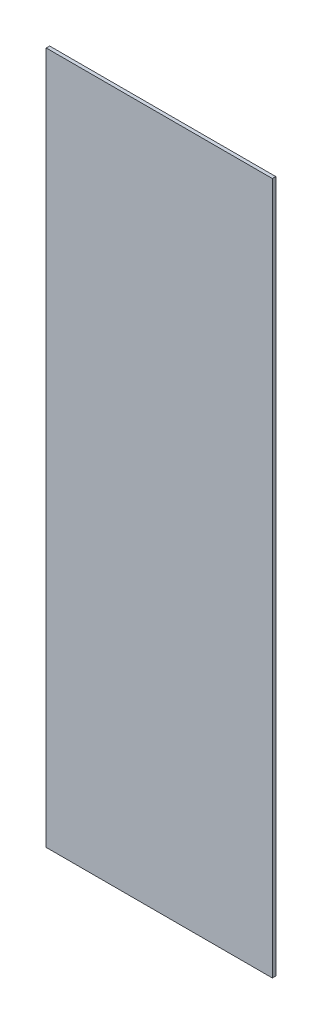
from build123d import *

# Parameters (mm, degrees)
ESQUISSE1_W        = 330
ESQUISSE1_H        = 1010.5
BOSS_EXTRU_1_DEPTH = 5


with BuildPart() as part:
    # Esquisse1 → Boss.-Extru.1 (new body)
    with BuildSketch(Plane.XY):
        with Locations((-146.909422309, -370.490549828)):
            Rectangle(ESQUISSE1_W, ESQUISSE1_H)
    extrude(amount=BOSS_EXTRU_1_DEPTH)


solid = part.part
